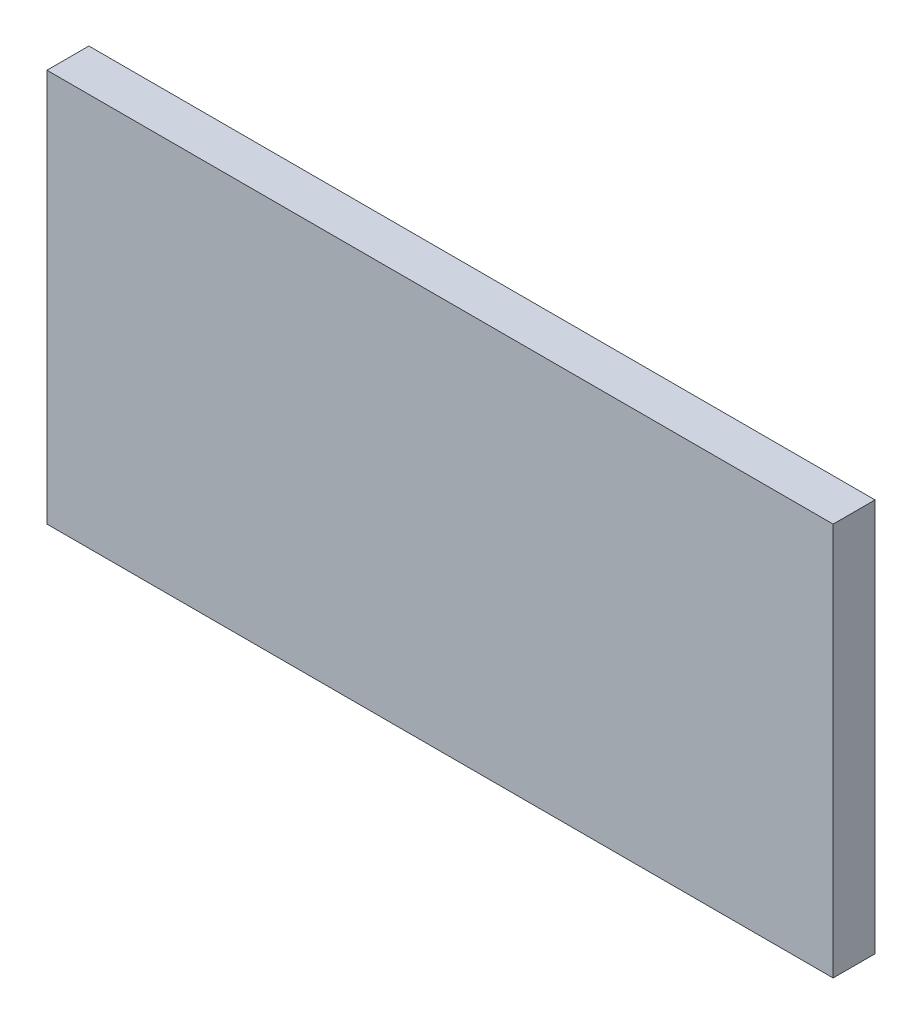
from build123d import *

# Parameters (mm, degrees)
SKETCH1_W           = 30
SKETCH1_H           = 15
BOSS_EXTRUDE1_DEPTH = 1.6


with BuildPart() as part:
    # Sketch1 → Boss-Extrude1 (new body)
    with BuildSketch(Plane.XY):
        Rectangle(SKETCH1_W, SKETCH1_H)
    extrude(amount=BOSS_EXTRUDE1_DEPTH)


solid = part.part
